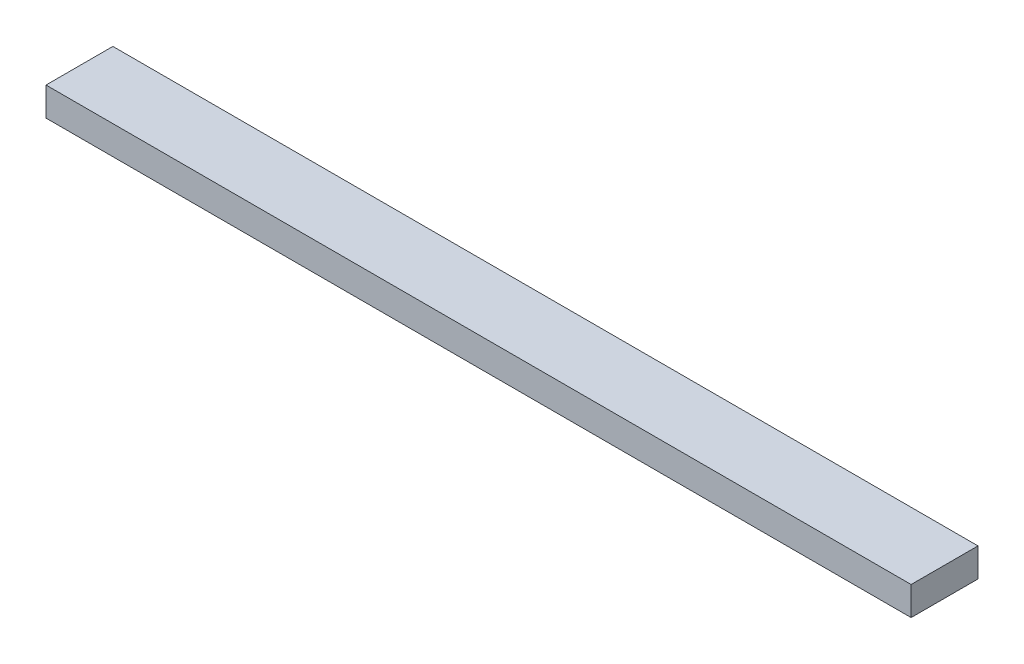
from build123d import *

# Parameters (mm, degrees)
SKETCH1_W           = 1150
SKETCH1_H           = 88.9
BOSS_EXTRUDE1_DEPTH = 38.1


with BuildPart() as part:
    # Sketch1 → Boss-Extrude1 (new body)
    with BuildSketch(Plane(origin=(0, 0, 0), x_dir=(1, 0, 0), z_dir=(0, 1, 0))):
        with Locations((575, -44.45)):
            Rectangle(SKETCH1_W, SKETCH1_H)
    extrude(amount=BOSS_EXTRUDE1_DEPTH)


solid = part.part
